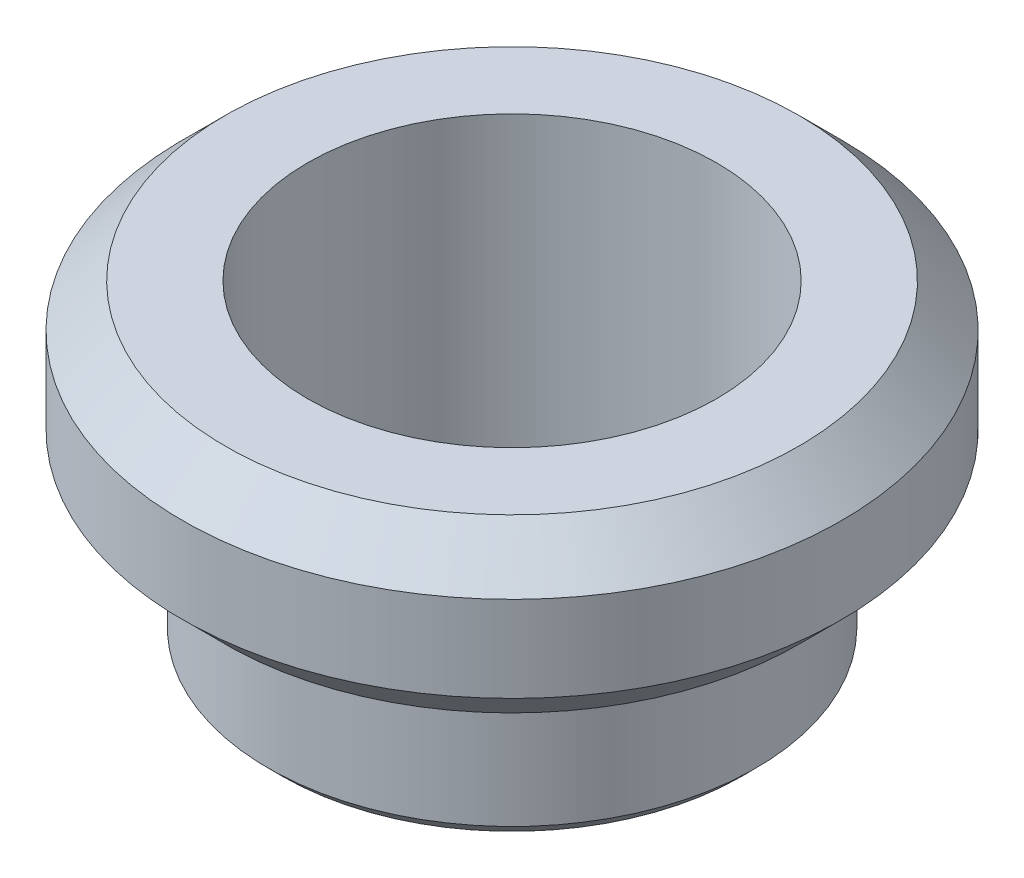
from build123d import *

# Parameters (mm, degrees)
SKETCH2_W     = 2.75
SKETCH2_H     = 10
CHAMFER1_SIZE = 3
CHAMFER2_SIZE = 1


with BuildPart() as part:
    # Sketch2 → Revolve1 (revolve)
    with BuildSketch(Plane(origin=(0, 0, 0), x_dir=(0, 0, -1), z_dir=(1, 0, 0))):
        Polygon((14.3, 12), (14.3, 0), (17.05, 0), (23.05, 0), (23.05, 12), align=None)
        with Locations((15.675, -5)):
            Rectangle(SKETCH2_W, SKETCH2_H)
    revolve(axis=Axis((0, -11.25, 0), (0, 1, 0)))

    # Chamfer1
    chamfer1_edges = [part.edges().sort_by_distance(p)[0] for p in [
        (0, 12, 23.05),
        (0, 0, 23.05),
    ]]
    chamfer(chamfer1_edges, length=CHAMFER1_SIZE)

    # Chamfer2
    chamfer2_edges = [part.edges().sort_by_distance(p)[0] for p in [
        (0, -10, 17.05),
    ]]
    chamfer(chamfer2_edges, length=CHAMFER2_SIZE)


solid = part.part
